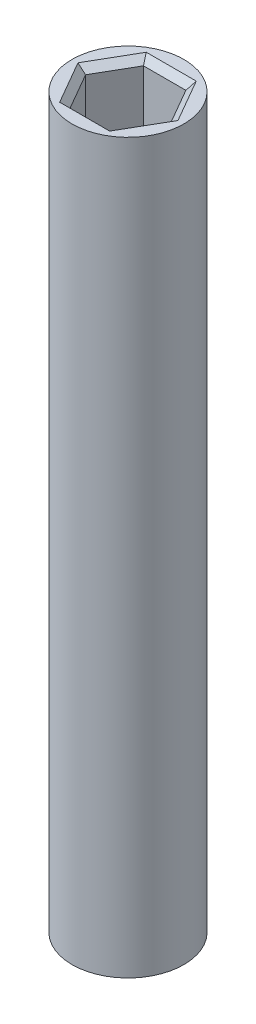
from build123d import *

# Parameters (mm, degrees)
SKETCH1_R           = 4.25
BOSS_EXTRUDE1_DEPTH = 55.3238373
CUT_EXTRUDE1_DEPTH  = 6.6
CHAMFER1_SIZE       = 0.5
CUT_EXTRUDE2_DEPTH  = 6.6
CHAMFER2_SIZE       = 0.5


with BuildPart() as part:
    # Sketch1 → Boss-Extrude1 (new body)
    with BuildSketch(Plane(origin=(0, 0, 0), x_dir=(1, 0, 0), z_dir=(0, 1, 0))):
        Circle(SKETCH1_R)
    extrude(amount=BOSS_EXTRUDE1_DEPTH)

    # Sketch2 → Cut-Extrude1 (cut)
    with BuildSketch(Plane(origin=(0, 55.3238373, 0), x_dir=(1, 0, 0), z_dir=(0, 1, 0))):
        Polygon((1.610807251, 2.79), (-1.610807251, 2.79), (-3.221614502, 0), (-1.610807251, -2.79), (1.610807251, -2.79), (3.221614502, 0), align=None)
    extrude(amount=-CUT_EXTRUDE1_DEPTH, mode=Mode.SUBTRACT)

    # Chamfer1
    chamfer1_edges = [part.edges().sort_by_distance(p)[0] for p in [
        (2.416210877, 55.3238373, -1.395),
        (0, 55.3238373, -2.79),
        (-2.416210877, 55.3238373, -1.395),
        (-2.416210877, 55.3238373, 1.395),
        (0, 55.3238373, 2.79),
        (2.416210877, 55.3238373, 1.395),
    ]]
    chamfer(chamfer1_edges, length=CHAMFER1_SIZE)

    # Sketch3 → Cut-Extrude2 (cut)
    with BuildSketch(Plane.XZ):
        Polygon((0, 3.221614502), (-2.79, 1.610807251), (-2.79, -1.610807251), (0, -3.221614502), (2.79, -1.610807251), (2.79, 1.610807251), align=None)
    extrude(amount=-CUT_EXTRUDE2_DEPTH, mode=Mode.SUBTRACT)

    # Chamfer2
    chamfer2_edges = [part.edges().sort_by_distance(p)[0] for p in [
        (1.395, 0, 2.416210877),
        (-1.395, 0, 2.416210877),
        (-2.79, 0, 0),
        (-1.395, 0, -2.416210877),
        (1.395, 0, -2.416210877),
        (2.79, 0, 0),
    ]]
    chamfer(chamfer2_edges, length=CHAMFER2_SIZE)


solid = part.part
